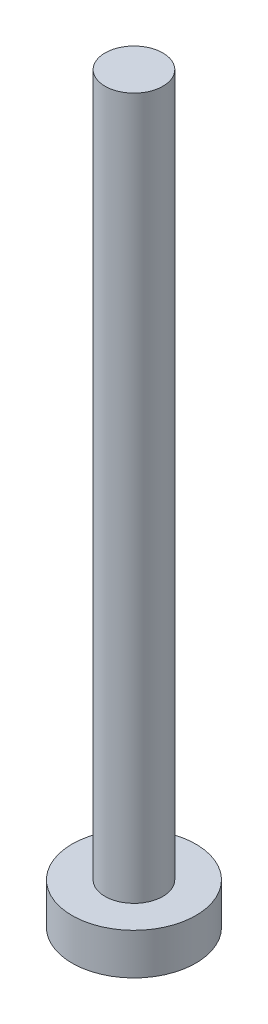
from build123d import *


with BuildPart() as part:
    # Sketch1 → Revolve1 (revolve)
    with BuildSketch(Plane.XY):
        Polygon((-1.4, 2), (-1.4, 36), (0, 36), (0, 0), (-3, 0), (-3, 2), align=None)
    revolve(axis=Axis((0, 36, 0), (0, -1, 0)))


solid = part.part
